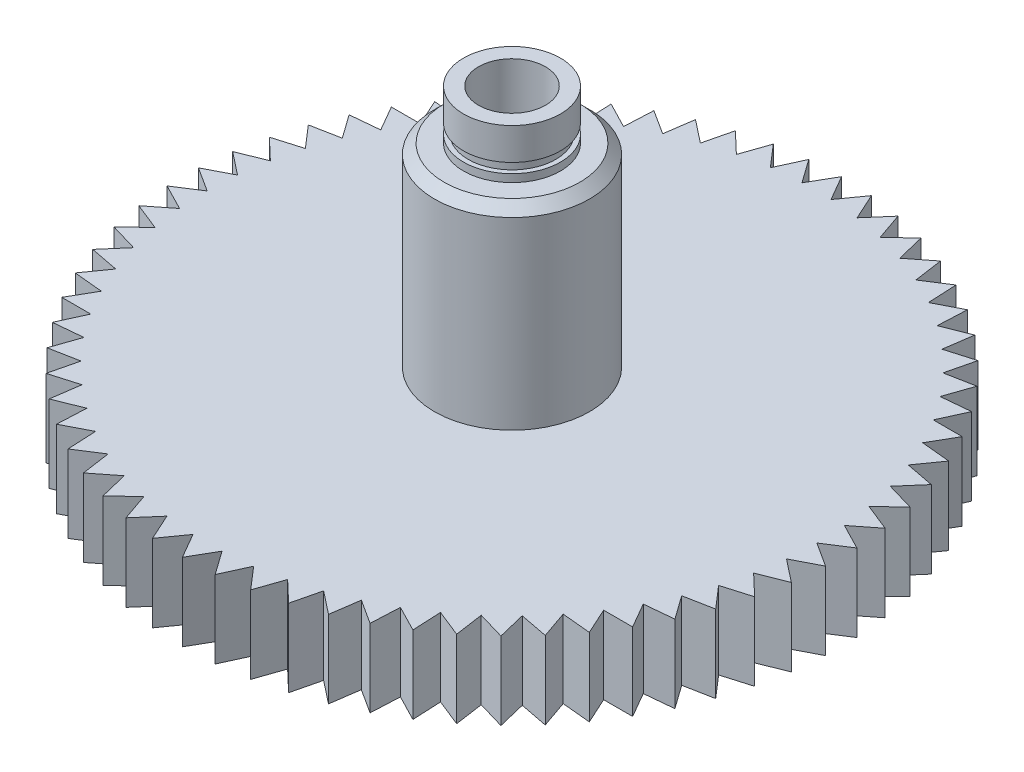
from build123d import *

# Parameters (mm, degrees)
BOSS_EXTRUDE1_DEPTH = 4
SKETCH2_R           = 4
BOSS_EXTRUDE2_DEPTH = 12.55
SKETCH3_R           = 4
SKETCH3_R_2         = 2.5
CUT_EXTRUDE1_DEPTH  = 2.55
CUT_EXTRUDE2_REACH  = 18.55
SKETCH4_R           = 1.725
CUT_EXTRUDE3_START  = -1.65
SKETCH5_R           = 2.5
SKETCH5_R_2         = 2.259704792
CUT_EXTRUDE3_DEPTH  = 0.5
CHAMFER1_SIZE       = 0.5
SKETCH6_R           = 3.064739397
SKETCH6_R_2         = 1.725
BOSS_EXTRUDE3_DEPTH = 3.65
SKETCH7_R           = 3.064739397
SKETCH7_R_2         = 2.5
CUT_EXTRUDE5_DEPTH  = 2.5
CUT_EXTRUDE6_START  = -1.65
SKETCH8_R           = 2.5
SKETCH8_R_2         = 2.259704792
CUT_EXTRUDE6_DEPTH  = 0.5
SKETCH9_R           = 4
BOSS_EXTRUDE4_DEPTH = 1.15


with BuildPart() as part:
    # Sketch1 → Boss-Extrude1 (new body)
    with BuildSketch(Plane(origin=(0, 0, 0), x_dir=(1, 0, 0), z_dir=(0, 1, 0))):
        Polygon((0, 17), (0.748086847, 15.704275572), (1.615952736, 16.923022684), (2.237485751, 15.562055221), (3.217271154, 16.692787853), (3.706621637, 15.278902488), (4.789453466, 16.311380551), (5.142189784, 14.857381647), (6.318261746, 15.782254861), (6.531189464, 14.301310058), (7.789850869, 15.110202627), (7.86104168, 13.61572359), (9.190893897, 14.301310058), (9.119703086, 12.806831021), (10.508702766, 13.362902611), (10.295775048, 11.881957807), (11.731343195, 12.303478648), (11.378606878, 10.849479744), (12.847742764, 11.132632477), (12.358392281, 9.718747111), (13.847791185, 9.860967463), (13.22625817, 8.5), (14.722431864, 8.5), (13.974345017, 7.204275572), (15.463743921, 7.062055221), (14.595878032, 5.84330811), (16.065013918, 5.560155376), (15.085228515, 4.429422744), (16.520796662, 4.007901904), (15.437964832, 2.97542384), (16.826964512, 2.419352251), (15.650892549, 1.494479037), (16.980744766, 0.808892569), (15.72208336, 0), (16.980744766, -0.808892569), (15.650892549, -1.494479037), (16.826964512, -2.419352251), (15.437964832, -2.97542384), (16.520796662, -4.007901904), (15.085228515, -4.429422744), (16.065013918, -5.560155376), (14.595878032, -5.84330811), (15.463743921, -7.062055221), (13.974345017, -7.204275572), (14.722431864, -8.5), (13.22625817, -8.5), (13.847791185, -9.860967463), (12.358392281, -9.718747111), (12.847742764, -11.132632477), (11.378606878, -10.849479744), (11.731343195, -12.303478648), (10.295775048, -11.881957807), (10.508702766, -13.362902611), (9.119703086, -12.806831021), (9.190893897, -14.301310058), (7.86104168, -13.61572359), (7.789850869, -15.110202627), (6.531189464, -14.301310058), (6.318261746, -15.782254861), (5.142189784, -14.857381647), (4.789453466, -16.311380551), (3.706621637, -15.278902488), (3.217271154, -16.692787853), (2.237485751, -15.562055221), (1.615952736, -16.923022684), (0.748086847, -15.704275572), (0, -17), (-0.748086847, -15.704275572), (-1.615952736, -16.923022684), (-2.237485751, -15.562055221), (-3.217271154, -16.692787853), (-3.706621637, -15.278902488), (-4.789453466, -16.311380551), (-5.142189784, -14.857381647), (-6.318261746, -15.782254861), (-6.531189464, -14.301310058), (-7.789850869, -15.110202627), (-7.86104168, -13.61572359), (-9.190893897, -14.301310058), (-9.119703086, -12.806831021), (-10.508702766, -13.362902611), (-10.295775048, -11.881957807), (-11.731343195, -12.303478648), (-11.378606878, -10.849479744), (-12.847742764, -11.132632477), (-12.358392281, -9.718747111), (-13.847791185, -9.860967463), (-13.22625817, -8.5), (-14.722431864, -8.5), (-13.974345017, -7.204275572), (-15.463743921, -7.062055221), (-14.595878032, -5.84330811), (-16.065013918, -5.560155376), (-15.085228515, -4.429422744), (-16.520796662, -4.007901904), (-15.437964832, -2.97542384), (-16.826964512, -2.419352251), (-15.650892549, -1.494479037), (-16.980744766, -0.808892569), (-15.72208336, 0), (-16.980744766, 0.808892569), (-15.650892549, 1.494479037), (-16.826964512, 2.419352251), (-15.437964832, 2.97542384), (-16.520796662, 4.007901904), (-15.085228515, 4.429422744), (-16.065013918, 5.560155376), (-14.595878032, 5.84330811), (-15.463743921, 7.062055221), (-13.974345017, 7.204275572), (-14.722431864, 8.5), (-13.22625817, 8.5), (-13.847791185, 9.860967463), (-12.358392281, 9.718747111), (-12.847742764, 11.132632477), (-11.378606878, 10.849479744), (-11.731343195, 12.303478648), (-10.295775048, 11.881957807), (-10.508702766, 13.362902611), (-9.119703086, 12.806831021), (-9.190893897, 14.301310058), (-7.86104168, 13.61572359), (-7.789850869, 15.110202627), (-6.531189464, 14.301310058), (-6.318261746, 15.782254861), (-5.142189784, 14.857381647), (-4.789453466, 16.311380551), (-3.706621637, 15.278902488), (-3.217271154, 16.692787853), (-2.237485751, 15.562055221), (-1.615952736, 16.923022684), (-0.748086847, 15.704275572), align=None)
    extrude(amount=BOSS_EXTRUDE1_DEPTH)

    # Sketch2 → Boss-Extrude2 (add)
    with BuildSketch(Plane(origin=(0, 4, 0), x_dir=(1, 0, 0), z_dir=(0, 1, 0))):
        Circle(SKETCH2_R)
    extrude(amount=BOSS_EXTRUDE2_DEPTH)

    # Sketch3 → Cut-Extrude1 (cut)
    with BuildSketch(Plane(origin=(0, 16.55, 0), x_dir=(1, 0, 0), z_dir=(0, 1, 0))):
        Circle(SKETCH3_R)
        Circle(SKETCH3_R_2, mode=Mode.SUBTRACT)
    extrude(amount=-CUT_EXTRUDE1_DEPTH, mode=Mode.SUBTRACT)

    # Sketch4 → Cut-Extrude2 (cut, up to next)
    with BuildSketch(Plane(origin=(0, 16.55, 0), x_dir=(1, 0, 0), z_dir=(0, 1, 0)), mode=Mode.PRIVATE) as cut_extrude2_sk1:
        Circle(SKETCH4_R)
    cut_extrude2_tool1 = extrude(cut_extrude2_sk1.sketch, amount=-CUT_EXTRUDE2_REACH, mode=Mode.PRIVATE) & part.part
    add(cut_extrude2_tool1.solids().sort_by_distance((0, 16.55, 0))[0], mode=Mode.SUBTRACT)

    # Sketch5 → Cut-Extrude3 (cut)
    with BuildSketch(Plane(origin=(0, 16.55, 0), x_dir=(1, 0, 0), z_dir=(0, 1, 0)).offset(CUT_EXTRUDE3_START)):
        Circle(SKETCH5_R)
        Circle(SKETCH5_R_2, mode=Mode.SUBTRACT)
    extrude(amount=-CUT_EXTRUDE3_DEPTH, mode=Mode.SUBTRACT)

    # Chamfer1
    chamfer1_edges = [part.edges().sort_by_distance(p)[0] for p in [
        (-4, 14, 0),
    ]]
    chamfer(chamfer1_edges, length=CHAMFER1_SIZE)

    # Sketch6 → Boss-Extrude3 (add)
    with BuildSketch(Plane(origin=(0, 0, 0), x_dir=(-1, 0, 0), z_dir=(0, -1, 0))):
        Circle(SKETCH6_R)
        Circle(SKETCH6_R_2, mode=Mode.SUBTRACT)
    extrude(amount=BOSS_EXTRUDE3_DEPTH)

    # Sketch7 → Cut-Extrude5 (cut)
    with BuildSketch(Plane(origin=(0, -3.65, 0), x_dir=(-1, 0, 0), z_dir=(0, -1, 0))):
        Circle(SKETCH7_R)
        Circle(SKETCH7_R_2, mode=Mode.SUBTRACT)
    extrude(amount=-CUT_EXTRUDE5_DEPTH, mode=Mode.SUBTRACT)

    # Sketch8 → Cut-Extrude6 (cut)
    with BuildSketch(Plane.XZ.offset(3.65).offset(CUT_EXTRUDE6_START)):
        Circle(SKETCH8_R)
        Circle(SKETCH8_R_2, mode=Mode.SUBTRACT)
    extrude(amount=-CUT_EXTRUDE6_DEPTH, mode=Mode.SUBTRACT)

    # Sketch9 → Boss-Extrude4 (add)
    with BuildSketch(Plane.XZ):
        Circle(SKETCH9_R)
    extrude(amount=BOSS_EXTRUDE4_DEPTH)


solid = part.part
